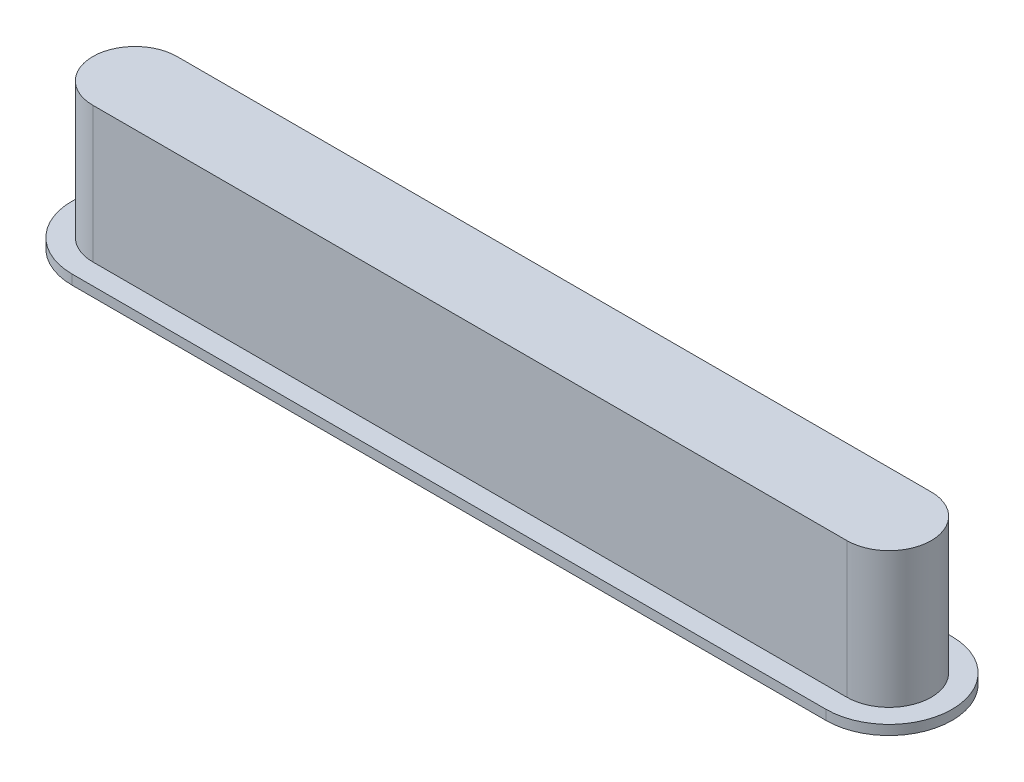
from build123d import *

# Parameters (mm, degrees)
BOSS_EXTRUDE1_DEPTH = 3.556
BOSS_EXTRUDE2_DEPTH = 0.254


with BuildPart() as part:
    # Sketch1 → Boss-Extrude1 (new body)
    with BuildSketch(Plane(origin=(0, 0, 0), x_dir=(1, 0, 0), z_dir=(0, 1, 0))):
        with BuildLine():
            Line((-9.8806, 1.1049), (9.8806, 1.1049))
            ThreePointArc((9.8806, 1.1049), (10.9855, 0), (9.8806, -1.1049))
            Line((9.8806, -1.1049), (-9.8806, -1.1049))
            ThreePointArc((-9.8806, -1.1049), (-10.9855, 0), (-9.8806, 1.1049))
        make_face()
    extrude(amount=BOSS_EXTRUDE1_DEPTH)

    # Sketch3 → Boss-Extrude2 (add)
    with BuildSketch(Plane(origin=(0, 0, 0), x_dir=(1, 0, 0), z_dir=(0, 1, 0))):
        with BuildLine():
            Line((-9.8806, 1.651), (9.8806, 1.651))
            ThreePointArc((9.8806, 1.651), (11.5316, 0), (9.8806, -1.651))
            Line((9.8806, -1.651), (-9.8806, -1.651))
            ThreePointArc((-9.8806, -1.651), (-11.5316, 0), (-9.8806, 1.651))
        make_face()
    extrude(amount=-BOSS_EXTRUDE2_DEPTH)


solid = part.part
